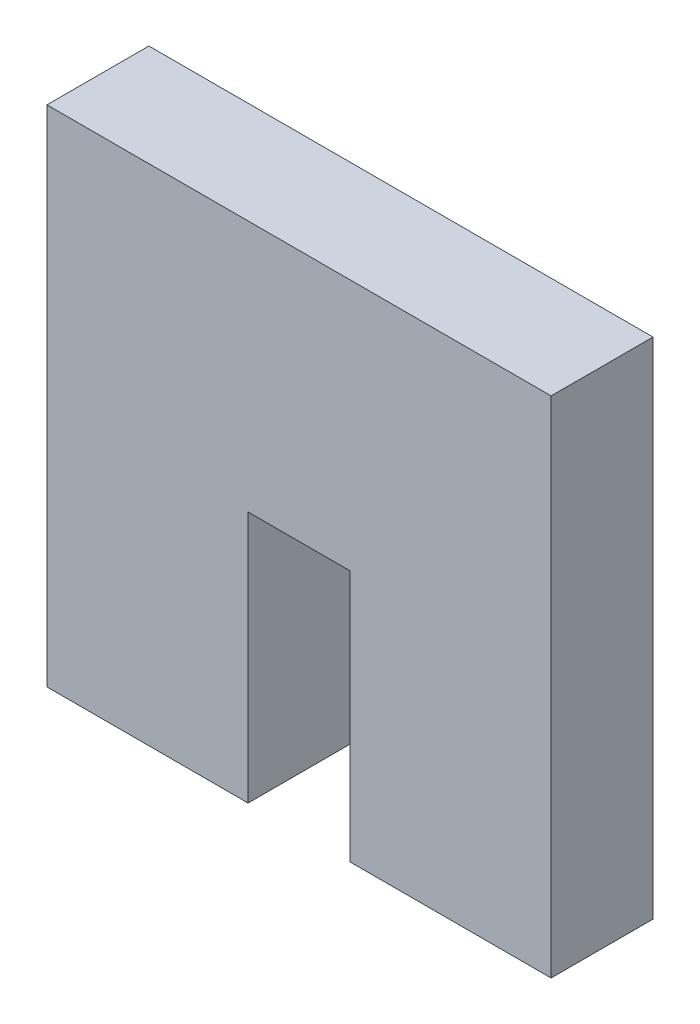
from build123d import *

# Parameters (mm, degrees)
BOSS_EXTRUDE1_DEPTH = 4.318


with BuildPart() as part:
    # Sketch1 → Boss-Extrude1 (new body)
    with BuildSketch(Plane.XY):
        Polygon((0, 0), (8.521, 0), (8.521, 10.68), (12.839, 10.68), (12.839, 0), (21.36, 0), (21.36, 21.36), (0, 21.36), align=None)
    extrude(amount=BOSS_EXTRUDE1_DEPTH)


solid = part.part
